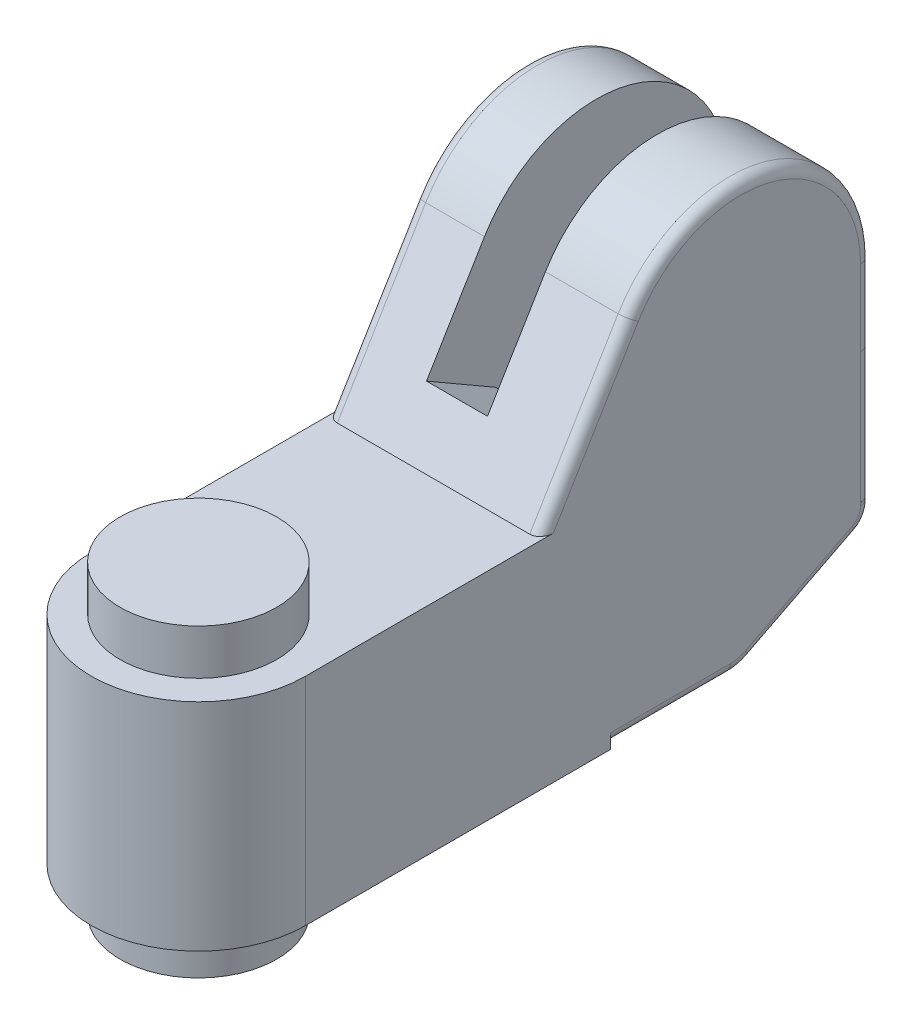
from build123d import *

# Parameters (mm, degrees)
BOSS_EXTRUDE1_DEPTH      = 12.3
CUT_EXTRUDE1_DEPTH       = 25.8
SKETCH3_R                = 9
BOSS_EXTRUDE2_DEPTH      = 5
BOSS_EXTRUDE2_DEPTH_BACK = 30
CUT_EXTRUDE2_START       = -8
CUT_EXTRUDE2_DEPTH       = 7
SKETCH5_R                = 5
CUT_EXTRUDE3_DEPTH       = 14
CUT_EXTRUDE3_DEPTH_BACK  = 7
CUT_EXTRUDE4_DEPTH       = 1.25
FILLET1_R                = 1.25
SKETCH8_R                = 3.2
CUT_EXTRUDE6_DEPTH       = 25.9
SKETCH7_R                = 1.5
SKETCH7_W                = 24.6
SKETCH7_H                = 0.01
CUT_EXTRUDE5_DEPTH       = 1.25
SKETCH9_R                = 2.75
BOSS_EXTRUDE3_DEPTH      = 2
CHAMFER1_SIZE            = 0.25
SKETCH10_R               = 1.25
CUT_EXTRUDE7_DEPTH       = 0.1
CUT_EXTRUDE7_TAPER       = 45
SKETCH11_W               = 0.4
SKETCH11_H               = 2.26495033
CUT_EXTRUDE8_DEPTH       = 0.2
CUT_EXTRUDE8_TAPER       = 5
SKETCH12_R               = 1.75
CUT_EXTRUDE9_DEPTH       = 0.1
CUT_EXTRUDE9_TAPER       = 45
SKETCH13_W               = 3.261901286
SKETCH13_H               = 0.5
CUT_EXTRUDE10_DEPTH      = 0.2
CUT_EXTRUDE10_TAPER      = 5


with BuildPart() as part:
    # Sketch1 → Boss-Extrude1 (new body, symmetric)
    with BuildSketch(Plane(origin=(0, 0, 0), x_dir=(0, 0, -1), z_dir=(1, 0, 0))):
        with BuildLine():
            Line((-12.3, 0), (35, 0))
            Line((35, 0), (35, 0.4))
            Line((35, 0.4), (48.799606205, 0.4))
            ThreePointArc((48.799606205, 0.4), (49.966833024, 0.538150398), (51.069558703, 0.944967379))
            Line((51.069558703, 0.944967379), (63.361971499, 7.208264534))
            ThreePointArc((63.361971499, 7.208264534), (64.557920493, 8.313788413), (65, 9.881284107))
            Line((65, 9.881284107), (65, 33.9))
            ThreePointArc((65, 33.9), (54.018869932, 48.35159799), (37.153508737, 41.643879017))
            Line((37.153508737, 41.643879017), (27, 24.8))
            Line((27, 24.8), (-12.3, 24.8))
            Line((-12.3, 24.8), (-12.3, 0))
        make_face()
    extrude(amount=BOSS_EXTRUDE1_DEPTH, both=True)

    # Sketch2 → Cut-Extrude1 (cut, through all)
    with BuildSketch(Plane(origin=(0, 24.8, 0), x_dir=(1, 0, 0), z_dir=(0, 1, 0))):
        with BuildLine():
            Line((-12.3, 0), (-12.3, -13.3))
            Line((-12.3, -13.3), (12.3, -13.3))
            Line((12.3, -13.3), (12.3, 0))
            ThreePointArc((12.3, 0), (0, -12.3), (-12.3, 0))
        make_face()
    extrude(amount=-CUT_EXTRUDE1_DEPTH, mode=Mode.SUBTRACT)

    # Sketch3 → Boss-Extrude2 (add, two sides)
    with BuildSketch(Plane.XZ) as boss_extrude2_sk:
        Circle(SKETCH3_R)
    extrude(amount=BOSS_EXTRUDE2_DEPTH)
    extrude(boss_extrude2_sk.sketch, amount=-BOSS_EXTRUDE2_DEPTH_BACK)

    # Sketch4 → Cut-Extrude2 (cut)
    with BuildSketch(Plane.ZY.offset(12.3).offset(CUT_EXTRUDE2_START)):
        with BuildLine():
            Line((-38.427724473, 26.020758976), (-30.496246358, 30.6))
            Line((-30.496246358, 30.6), (-37.153508737, 41.643879017))
            ThreePointArc((-37.153508737, 41.643879017), (-54.018869932, 48.35159799), (-65, 33.9))
            Line((-65, 33.9), (-65, 22.006887866))
            Line((-65, 22.006887866), (-63.8, 22.006887866))
            ThreePointArc((-63.8, 22.006887866), (-59.302339897, 21.905283192), (-54.941176471, 20.800962818))
            ThreePointArc((-54.941176471, 20.800962818), (-45.780469617, 20.551008902), (-38.427724473, 26.020758976))
        make_face()
    extrude(amount=-CUT_EXTRUDE2_DEPTH, mode=Mode.SUBTRACT)

    # Sketch5 → Cut-Extrude3 (cut, two sides)
    with BuildSketch(Plane.ZY.offset(-2.7)) as cut_extrude3_sk:
        with Locations((-50, 33.9)):
            Circle(SKETCH5_R)
    extrude(amount=CUT_EXTRUDE3_DEPTH, mode=Mode.SUBTRACT)
    extrude(cut_extrude3_sk.sketch, amount=-CUT_EXTRUDE3_DEPTH_BACK, mode=Mode.SUBTRACT)

    # Sketch6 → Cut-Extrude4 (cut)
    with BuildSketch(Plane.ZY.offset(12.3)):
        with BuildLine():
            Line((-35, 0.4), (-35, 14.4))
            Line((-35, 14.4), (-41, 14.4))
            ThreePointArc((-41, 14.4), (-42.414213562, 14.985786438), (-43, 16.4))
            Line((-43, 16.4), (-43, 33.9))
            ThreePointArc((-43, 33.9), (-50, 40.9), (-57, 33.9))
            Line((-57, 33.9), (-57, 3.966678146))
            Line((-57, 3.966678146), (-56.99, 3.961582892))
            Line((-56.99, 3.961582892), (-56.99, 33.9))
            ThreePointArc((-56.99, 33.9), (-50, 40.89), (-43.01, 33.9))
            Line((-43.01, 33.9), (-43.01, 16.4))
            ThreePointArc((-43.01, 16.4), (-42.42128463, 14.97871537), (-41, 14.39))
            Line((-41, 14.39), (-35.01, 14.39))
            Line((-35.01, 14.39), (-35.01, 0.4))
            Line((-35.01, 0.4), (-35, 0.4))
        make_face()
    extrude(amount=-CUT_EXTRUDE4_DEPTH, mode=Mode.SUBTRACT)

    # Fillet1
    fillet1_edges = [part.edges().sort_by_distance(p)[0] for p in [
        (12.3, 0.4, -41.899803102),
        (12.3, 0.538150398, -49.966833024),
        (12.3, 4.076615957, -57.215765101),
        (12.3, 8.313788413, -64.557920493),
        (12.3, 33.221939508, -32.076754368),
        (12.3, 48.35159799, -54.018869932),
        (-12.3, 33.221939508, -32.076754368),
        (-12.3, 48.35159799, -54.018869932),
        (-12.3, 21.890642053, -65),
        (-12.3, 8.313788413, -64.557920493),
        (-12.3, 2.453275136, -54.029779352),
        (-12.3, 0.538150398, -49.966833024),
        (12.3, 21.890642053, -65),
        (-12.3, 5.58747134, -60.18098575),
        (-12.3, 0.4, -41.904803102),
    ]]
    fillet(fillet1_edges, radius=FILLET1_R)

    # Sketch8 → Cut-Extrude6 (cut)
    with BuildSketch(Plane(origin=(0, 0, -65), x_dir=(-1, 0, 0), z_dir=(0, 0, -1))):
        with Locations((0.8, 4)):
            Circle(SKETCH8_R)
        Polygon((-4.122649731, 15.6), (-3.545299462, 16.6), (-4.122649731, 17.6), (-5.277350269, 17.6), (-5.854700538, 16.6), (-5.277350269, 15.6), align=None)
        Polygon((6.877350269, 15.6), (7.454700538, 16.6), (6.877350269, 17.6), (5.722649731, 17.6), (5.145299462, 16.6), (5.722649731, 15.6), align=None)
    extrude(amount=-CUT_EXTRUDE6_DEPTH, mode=Mode.SUBTRACT)

    # Sketch7 → Cut-Extrude5 (cut)
    with BuildSketch(Plane(origin=(0, 0, -65), x_dir=(-1, 0, 0), z_dir=(0, 0, -1))):
        with Locations((-4.7, 16.6)):
            Circle(SKETCH7_R)
        with Locations((6.3, 16.6)):
            Circle(SKETCH7_R)
        with Locations((0, 10.205)):
            Rectangle(SKETCH7_W, SKETCH7_H)
        Polygon((-12.3, 25.2), (12.3, 25.2), (12.3, 25.19), (4.31, 25.19), (4.31, 21.996887866), (-2.71, 21.996887866), (-2.71, 25.19), (-12.3, 25.19), align=None)
    extrude(amount=-CUT_EXTRUDE5_DEPTH, mode=Mode.SUBTRACT)

    # Sketch9 → Boss-Extrude3 (add)
    with BuildSketch(Plane(origin=(0, 0, -39.1), x_dir=(-1, 0, 0), z_dir=(0, 0, -1))):
        with Locations((0.8, 4)):
            Circle(SKETCH9_R)
        Polygon((1.377350269, 5), (0.222649731, 5), (-0.354700538, 4), (0.222649731, 3), (1.377350269, 3), (1.954700538, 4), align=None, mode=Mode.SUBTRACT)
    extrude(amount=BOSS_EXTRUDE3_DEPTH)

    # Chamfer1
    chamfer1_edges = [part.edges().sort_by_distance(p)[0] for p in [
        (1.95, 4, -41.1),
    ]]
    chamfer(chamfer1_edges, length=CHAMFER1_SIZE)

    # Sketch10 → Cut-Extrude7 (cut)
    with BuildSketch(Plane(origin=(0, 0, -65), x_dir=(-1, 0, 0), z_dir=(0, 0, -1))):
        with Locations((-8.2, 21.6)):
            Circle(SKETCH10_R)
        with Locations((9.8, 21.6)):
            Circle(SKETCH10_R)
        with Locations((9.8, 11.6)):
            Circle(SKETCH10_R)
        with Locations((-8.2, 11.6)):
            Circle(SKETCH10_R)
    extrude(amount=-CUT_EXTRUDE7_DEPTH, taper=CUT_EXTRUDE7_TAPER, mode=Mode.SUBTRACT)

    # Sketch11 → Cut-Extrude8 (cut)
    with BuildSketch(Plane(origin=(0, 0, -64.9), x_dir=(-1, 0, 0), z_dir=(0, 0, -1))):
        with Locations((9.8, 21.6)):
            Rectangle(SKETCH11_W, SKETCH11_H)
        with Locations((-8.2, 21.6)):
            Rectangle(SKETCH11_W, SKETCH11_H)
        with Locations((-8.2, 11.6)):
            Rectangle(SKETCH11_W, SKETCH11_H)
        with Locations((9.8, 11.6)):
            Rectangle(SKETCH11_W, SKETCH11_H)
    extrude(amount=-CUT_EXTRUDE8_DEPTH, taper=CUT_EXTRUDE8_TAPER, mode=Mode.SUBTRACT)

    # Sketch12 → Cut-Extrude9 (cut)
    with BuildSketch(Plane.ZY.offset(12.3)):
        with Locations((-55, 7.4)):
            Circle(SKETCH12_R)
        with Locations((-40.5, 7.4)):
            Circle(SKETCH12_R)
    extrude(amount=-CUT_EXTRUDE9_DEPTH, taper=CUT_EXTRUDE9_TAPER, mode=Mode.SUBTRACT)

    # Sketch13 → Cut-Extrude10 (cut)
    with BuildSketch(Plane.ZY.offset(12.2)):
        with Locations((-40.5, 7.4)):
            Rectangle(SKETCH13_W, SKETCH13_H)
        with Locations((-55, 7.4)):
            Rectangle(SKETCH13_W, SKETCH13_H)
    extrude(amount=-CUT_EXTRUDE10_DEPTH, taper=CUT_EXTRUDE10_TAPER, mode=Mode.SUBTRACT)


solid = part.part
